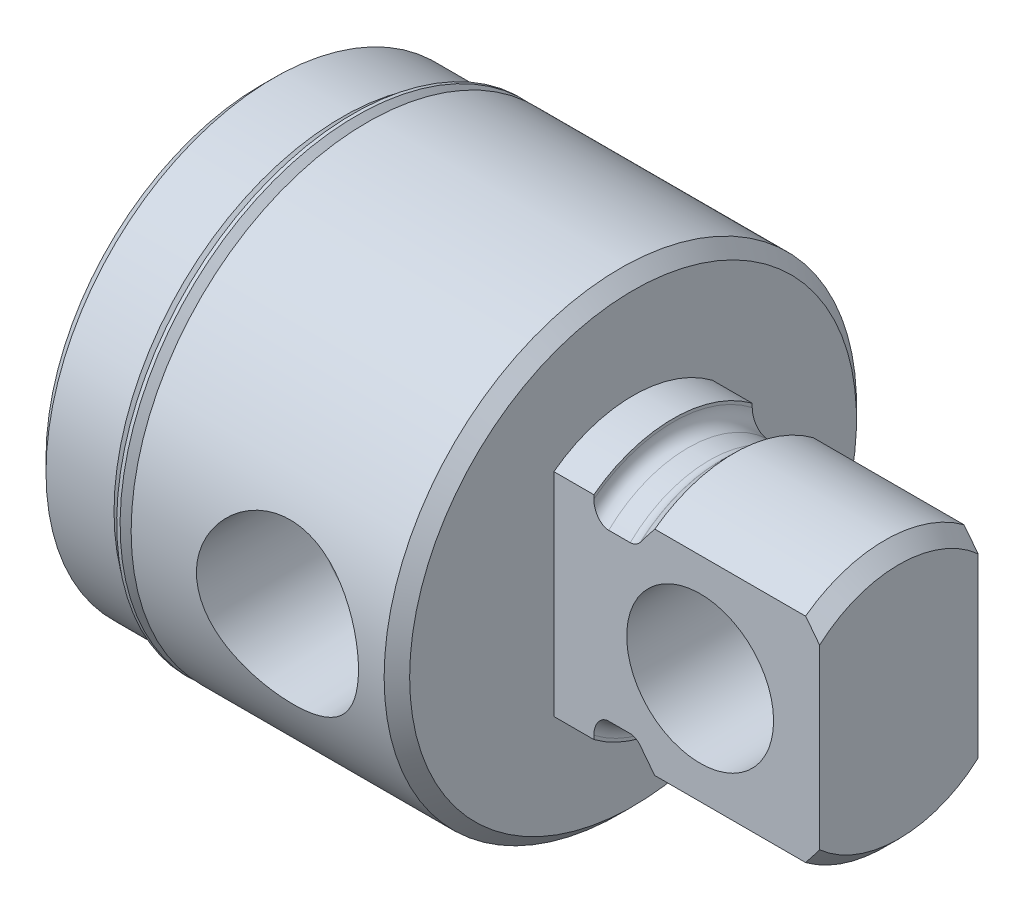
from build123d import *

# Parameters (mm, degrees)
SKETCH3_W               = 56.4388
SKETCH3_H               = 112.8776
SKETCH3_W_2             = 9.4615
SKETCH3_H_2             = 56.4388
CUT_EXTRUDE1_DEPTH      = 15.875
HOLE1_D                 = 9.525
HOLE1_DEPTH             = 20.955
HOLE1_TIP               = 2.749630657
CUT_EXTRUDE2_DEPTH      = 7.096125
CUT_EXTRUDE2_DEPTH_BACK = 7.096125
SKETCH8_R               = 4.38785


with BuildPart() as part:
    # Sketch1 → Revolve1 (revolve)
    with BuildSketch(Plane.XY):
        Polygon((0, 0), (0, 12.84605), (0.762, 13.60805), (4.826, 13.60805), (5.588, 12.84605), (6.35, 12.84605), (6.35, 14.1097), (21.463, 14.1097), (22.225, 13.3477), (22.225, 0), align=None)
    revolve(axis=Axis((22.225, 0, 0), (-1, 0, 0)))

    # Sketch2 → Revolve2 (revolve)
    with BuildSketch(Plane.XY):
        with BuildLine():
            Line((22.225, 0), (22.225, 7.90575))
            Line((22.225, 7.90575), (24.6126, 7.90575))
            Line((24.6126, 7.90575), (24.6126, 7.72795))
            ThreePointArc((24.6126, 7.72795), (24.872982072, 7.099332072), (25.5016, 6.83895))
            Line((25.5016, 6.83895), (26.7843, 6.83895))
            ThreePointArc((26.7843, 6.83895), (27.10530348, 6.898927826), (27.38299292, 7.0707683))
            Line((27.38299292, 7.0707683), (27.412917928, 7.09803))
            Line((27.412917928, 7.09803), (28.252387928, 7.9375))
            Line((28.252387928, 7.9375), (37.26053, 7.9375))
            Line((37.26053, 7.9375), (38.1, 7.09803))
            Line((38.1, 7.09803), (38.1, 0))
            Line((38.1, 0), (22.225, 0))
        make_face()
    revolve(axis=Axis((38.1, 0, 0), (-1, 0, 0)))

    # Sketch3 → Cut-Extrude1 (cut)
    with BuildSketch(Plane(origin=(38.1, 0, 0), x_dir=(0, 0, -1), z_dir=(1, 0, 0))):
        Rectangle(SKETCH3_W, SKETCH3_H)
        Rectangle(SKETCH3_W_2, SKETCH3_H_2, mode=Mode.SUBTRACT)
    extrude(amount=-CUT_EXTRUDE1_DEPTH, mode=Mode.SUBTRACT)

    # Hole1
    with Locations(Plane.ZY):
        with Locations((0, 0)):
            Hole(HOLE1_D / 2, depth=HOLE1_DEPTH)
            with Locations((0, 0, -(HOLE1_DEPTH + HOLE1_TIP / 2))):  # 120° drill point
                Cone(0, HOLE1_D / 2, HOLE1_TIP, mode=Mode.SUBTRACT)

    # Sketch6 → Cut-Revolve1 (revolve, cut)
    with BuildSketch(Plane(origin=(0, 0, 0), x_dir=(1, 0, 0), z_dir=(0, 0.9998476951563913, 0.01745240643728403))):
        Polygon((15.0876, 0), (19.710593378, 0), (19.710593378, -7.1755), (19.927075925, -14.1097), (15.0876, -14.1097), align=None)
    revolve(axis=Axis((15.0876, -0.246248219, 14.107551024), (0, 0.01745240643728403, -0.9998476951563913)), mode=Mode.SUBTRACT)

    # Sketch7 → Revolve3 (revolve)
    with BuildSketch(Plane.XY):
        with BuildLine():
            Line((5.48614893, 14.025531804), (6.227512806, 13.284167928))
            ThreePointArc((6.227512806, 13.284167928), (6.264710245, 13.194365367), (6.227512806, 13.104562806))
            Line((6.227512806, 13.104562806), (5.969, 12.84605))
            Line((5.969, 12.84605), (5.588, 12.84605))
            Line((5.588, 12.84605), (5.588, 12.59205))
            Line((5.588, 12.59205), (6.35, 12.59205))
            Line((6.35, 12.59205), (6.35, 13.44904893))
            Line((6.35, 13.44904893), (5.68934893, 14.1097))
            Line((5.68934893, 14.1097), (5.48614893, 14.1097))
            Line((5.48614893, 14.1097), (5.48614893, 14.025531804))
        make_face()
    revolve(axis=Axis((6.35, 0, 0), (-1, 0, 0)))

    # Sketch8 → Cut-Extrude2 (cut, two sides: drawn at the far end of the back side and taken through both)
    with BuildSketch(Plane.XY.offset(-CUT_EXTRUDE2_DEPTH_BACK)):
        with Locations((30.9626, 0)):
            Circle(SKETCH8_R)
    extrude(amount=CUT_EXTRUDE2_DEPTH + CUT_EXTRUDE2_DEPTH_BACK, mode=Mode.SUBTRACT)


solid = part.part
